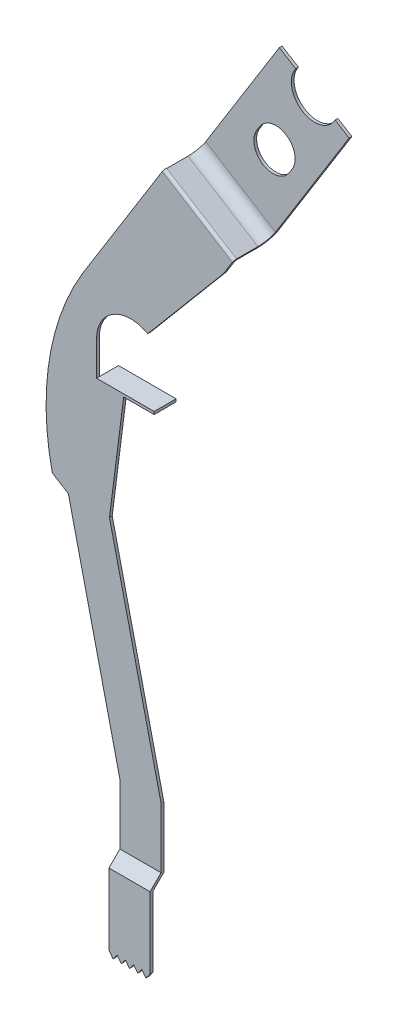
from build123d import *

# Parameters (mm, degrees)
BOSS_EXTRUDE1_DEPTH = 0.254
SKETCH3_W           = 3.81
SKETCH3_H           = 7.112
BOSS_EXTRUDE2_DEPTH = 1.016
BOSS_EXTRUDE3_DEPTH = 3.81
CUT_EXTRUDE1_DEPTH  = 3.81
CUT_EXTRUDE3_DEPTH  = 3.81
SKETCH9_W           = 5.334
SKETCH9_H           = 0.254
BOSS_EXTRUDE4_DEPTH = 2.032
BOSS_EXTRUDE5_DEPTH = 2.032
BOSS_EXTRUDE6_DEPTH = 7.62
SKETCH15_W          = 0.254
SKETCH15_H          = 13.969943058
CUT_EXTRUDE4_DEPTH  = 24.162808673
FILLET1_R           = 0.254
FILLET2_R           = 0.254
SKETCH16_R          = 2.159
CUT_EXTRUDE5_DEPTH  = 7.62
CUT_EXTRUDE6_DEPTH  = 7.62


with BuildPart() as part:
    # Sketch2 → Boss-Extrude1 (new body)
    with BuildSketch(Plane.XY):
        with BuildLine():
            Line((0, 7.62), (0, 0))
            Line((0, 0), (3.81, 0))
            Line((3.81, 0), (3.81, 13.716))
            Line((3.81, 13.716), (-0.967403026, 34.249561414))
            Line((-0.967403026, 34.249561414), (0.377089259, 44.819493706))
            Line((0.377089259, 44.819493706), (-2.162910741, 44.819493706))
            Line((-2.162910741, 44.819493706), (-2.162910741, 47.994493706))
            ThreePointArc((-2.162910741, 47.994493706), (-0.584766227, 50.738701708), (2.580823154, 50.754873928))
            Line((2.580823154, 50.754873928), (9.612257003, 59.112446663))
            Line((9.612257003, 59.112446663), (17.936769995, 72.485209152))
            Line((17.936769995, 72.485209152), (16.427333856, 73.424829575))
            ThreePointArc((16.427333856, 73.424829575), (15.208368205, 71.757285785), (13.146272514, 71.877039345))
            ThreePointArc((13.146272514, 71.877039345), (12.149333877, 73.408865168), (12.684466147, 75.156437899))
            Line((12.684466147, 75.156437899), (11.175030007, 76.096058323))
            Line((11.175030007, 76.096058323), (2.122651116, 61.554028899))
            Line((2.122651116, 61.554028899), (-3.456202303, 52.591981292))
            ThreePointArc((-3.456202303, 52.591981292), (-6.537615376, 44.154125487), (-6.264635755, 35.175372833))
            Line((-6.264635755, 35.175372833), (-4.777403026, 34.249561414))
            Line((-4.777403026, 34.249561414), (0, 13.716))
            Line((0, 13.716), (0, 7.62))
        make_face()
    extrude(amount=BOSS_EXTRUDE1_DEPTH)

    # Sketch3 → Boss-Extrude2 (add)
    with BuildSketch(Plane.XY.offset(0.254)):
        with Locations((1.905, 3.556)):
            Rectangle(SKETCH3_W, SKETCH3_H)
    extrude(amount=BOSS_EXTRUDE2_DEPTH)

    # Sketch4 → Boss-Extrude3 (add)
    with BuildSketch(Plane(origin=(3.81, 0, 0), x_dir=(0, 0, -1), z_dir=(1, 0, 0))):
        Polygon((-1.27, 7.112), (-0.254, 8.128), (-0.254, 7.112), align=None)
    extrude(amount=-BOSS_EXTRUDE3_DEPTH)

    # Sketch5 → Cut-Extrude1 (cut)
    with BuildSketch(Plane(origin=(3.81, 0, 0), x_dir=(0, 0, -1), z_dir=(1, 0, 0))):
        Polygon((0, 0), (-1.016, 0), (-1.016, 7.006789755), (0, 8.022789755), align=None)
    extrude(amount=-CUT_EXTRUDE1_DEPTH, mode=Mode.SUBTRACT)

    # Sketch7 → Cut-Extrude3 (cut)
    with BuildSketch(Plane.XY.offset(1.27)):
        Polygon((0, 0.508), (0.381, 0), (0.762, 0.508), (1.143, 0), (1.524, 0.508), (1.905, 0), (2.286, 0.508), (2.667, 0), (3.048, 0.508), (3.429, 0), (3.81, 0.508), (3.81, 0), (0, 0), align=None)
    extrude(amount=-CUT_EXTRUDE3_DEPTH, mode=Mode.SUBTRACT)

    # Sketch9 → Boss-Extrude4 (add)
    with BuildSketch(Plane.XY.offset(0.254)):
        with Locations((0.504089259, 44.692493706)):
            Rectangle(SKETCH9_W, SKETCH9_H)
    extrude(amount=-BOSS_EXTRUDE4_DEPTH)

    # Sketch10 → Boss-Extrude5 (add)
    with BuildSketch(Plane(origin=(0, 0, 0), x_dir=(-1, 0, 0), z_dir=(0, 0, -1))):
        with BuildLine():
            Line((5.928887496, 35.253489079), (6.264635755, 35.175372833))
            ThreePointArc((6.264635755, 35.175372833), (6.537615376, 44.154125487), (3.456202303, 52.591981292))
            Line((3.456202303, 52.591981292), (-3.926529596, 64.451836675))
            Line((-3.926529596, 64.451836675), (-4.148451246, 64.313690973))
            Line((-4.148451246, 64.313690973), (3.202180271, 52.505402665))
            ThreePointArc((3.202180271, 52.505402665), (6.248425743, 44.145431055), (5.928887496, 35.253489079))
        make_face()
    extrude(amount=BOSS_EXTRUDE5_DEPTH)

    # Sketch13 → Boss-Extrude6 (add)
    with BuildSketch(Plane(origin=(-19.592819025, 12.196483461, 0), x_dir=(0, 0, -1), z_dir=(0.84895171, -0.528470429, 0))):
        with BuildLine():
            Line((0, 56.791551712), (2.032, 56.791551712))
            ThreePointArc((2.032, 56.791551712), (2.930025612, 57.1635261), (3.302, 58.061551712))
            Line((3.302, 58.061551712), (3.302, 71.01549477))
            Line((3.302, 71.01549477), (3.048, 71.01549477))
            Line((3.048, 71.01549477), (3.048, 58.117392676))
            ThreePointArc((3.048, 58.117392676), (2.73406505, 57.359486662), (1.976159036, 57.045551712))
            Line((1.976159036, 57.045551712), (0, 57.045551712))
            Line((0, 57.045551712), (0, 56.791551712))
        make_face()
    extrude(amount=-BOSS_EXTRUDE6_DEPTH)

    # Sketch15 → Cut-Extrude4 (cut, through all)
    with BuildSketch(Plane(origin=(-19.592819025, 12.196483461, 0), x_dir=(0, 0, -1), z_dir=(0.84895171, -0.528470429, 0))):
        with Locations((-0.127, 64.030523241)):
            Rectangle(SKETCH15_W, SKETCH15_H)
    extrude(amount=-CUT_EXTRUDE4_DEPTH, mode=Mode.SUBTRACT)

    # Fillet1
    fillet1_edges = [part.edges().sort_by_distance(p)[0] for p in [
        (7.307414636, 62.646436259, 0.254),
    ]]
    fillet(fillet1_edges, radius=FILLET1_R)

    # Fillet2
    fillet2_edges = [part.edges().sort_by_distance(p)[0] for p in [
        (7.284143972, 62.361729674, 0),
    ]]
    fillet(fillet2_edges, radius=FILLET2_R)

    # Sketch16 → Cut-Extrude5 (cut)
    with BuildSketch(Plane.XY.offset(-3.048)):
        with Locations((14.737858035, 74.315544717)):
            Circle(SKETCH16_R)
    extrude(amount=-CUT_EXTRUDE5_DEPTH, mode=Mode.SUBTRACT)

    # Sketch17 → Cut-Extrude6 (cut)
    with BuildSketch(Plane.XY.offset(-3.048)):
        with BuildLine():
            Line((12.664355285, 67.379861092), (12.395892307, 66.948593623))
            ThreePointArc((12.395892307, 66.948593623), (9.946835744, 66.378777907), (9.377020028, 68.82783447))
            Line((9.377020028, 68.82783447), (9.645483006, 69.259101939))
            ThreePointArc((9.645483006, 69.259101939), (12.094539569, 69.828917655), (12.664355285, 67.379861092))
        make_face()
    extrude(amount=-CUT_EXTRUDE6_DEPTH, mode=Mode.SUBTRACT)


solid = part.part
